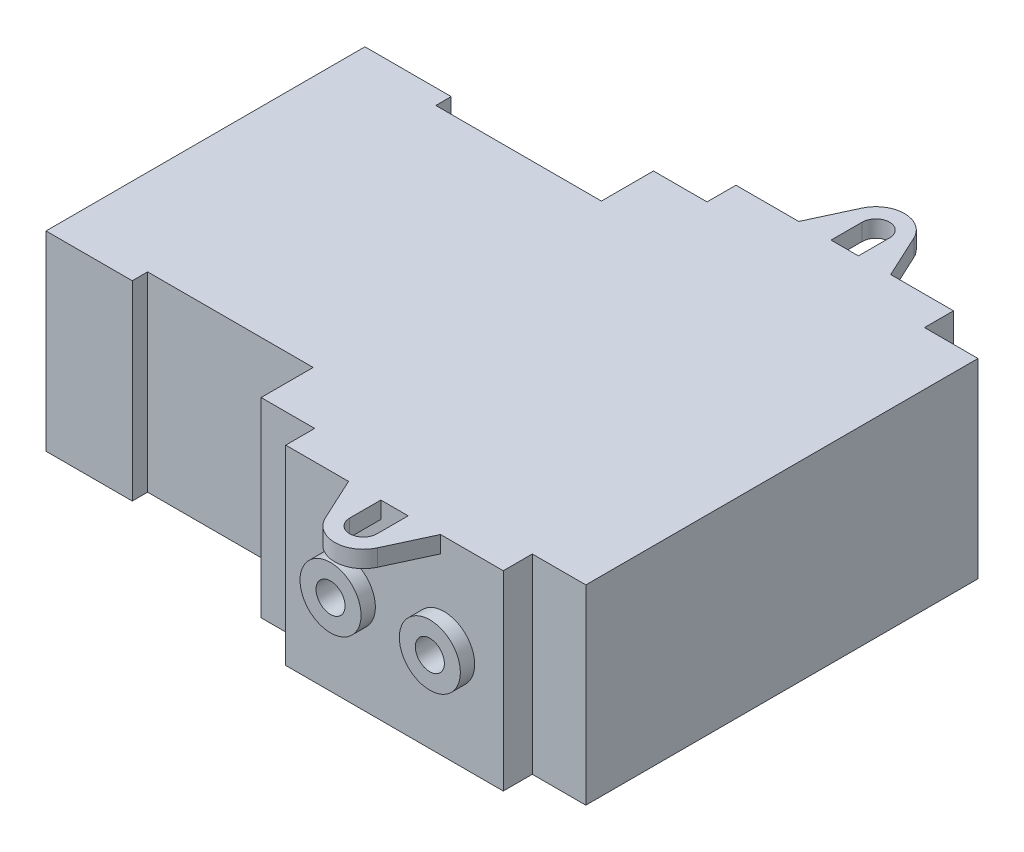
from build123d import *

# Parameters (mm, degrees)
BOSS_EXTRUDE1_DEPTH = 23.0378
SKETCH2_R           = 3.683
BOSS_EXTRUDE2_DEPTH = 1.7272
SKETCH3_R           = 1.7526
CUT_EXTRUDE1_DEPTH  = 58.8104
BOSS_EXTRUDE3_DEPTH = 2.032


with BuildPart() as part:
    # Sketch1 → Boss-Extrude1 (new body)
    with BuildSketch(Plane(origin=(0, 0, 0), x_dir=(1, 0, 0), z_dir=(0, 1, 0))):
        Polygon((-34.798, 19.2532), (-24.384, 19.2532), (-24.384, 17.399), (-4.3942, 17.399), (-4.3942, 23.684705806), (2.0701, 23.684705806), (2.0701, 27.178), (28.3337, 27.178), (28.3337, 23.6728), (34.798, 23.6728), (34.798, -23.6728), (28.3337, -23.6728), (28.3337, -27.178), (2.0701, -27.178), (2.0701, -23.684705806), (-4.3942, -23.684705806), (-4.3942, -17.399), (-24.384, -17.399), (-24.384, -19.2532), (-34.798, -19.2532), align=None)
    extrude(amount=BOSS_EXTRUDE1_DEPTH)

    # Sketch2 → Boss-Extrude2 (add)
    with BuildSketch(Plane.XY.offset(27.178)):
        with Locations((21.1963, 11.5189)):
            Circle(SKETCH2_R)
        with Locations((9.2075, 11.5189)):
            Circle(SKETCH2_R)
    boss_extrude2 = extrude(amount=BOSS_EXTRUDE2_DEPTH)

    # Mirror1: Boss-Extrude2 across plane
    add(boss_extrude2.mirror(Plane.XY))

    # Sketch3 → Cut-Extrude1 (cut, through all)
    with BuildSketch(Plane.XY.offset(28.9052)):
        with Locations((21.1963, 11.5189)):
            Circle(SKETCH3_R)
        with Locations((9.2075, 11.5189)):
            Circle(SKETCH3_R)
    extrude(amount=-CUT_EXTRUDE1_DEPTH, mode=Mode.SUBTRACT)

    # Sketch4 → Boss-Extrude3 (add)
    with BuildSketch(Plane(origin=(0, 23.0378, 0), x_dir=(1, 0, 0), z_dir=(0, 1, 0))):
        with BuildLine():
            Line((13.5509, -27.178), (9.652, -27.178))
            Line((9.652, -27.178), (12.067809158, -32.389905736))
            ThreePointArc((12.067809158, -32.389905736), (15.2019, -34.3916), (18.335990842, -32.389905736))
            Line((18.335990842, -32.389905736), (20.7518, -27.178))
            Line((20.7518, -27.178), (16.8529, -27.178))
            Line((16.8529, -27.178), (16.8529, -30.9372))
            ThreePointArc((16.8529, -30.9372), (15.2019, -32.5882), (13.5509, -30.9372))
            Line((13.5509, -30.9372), (13.5509, -27.178))
        make_face()
        with BuildLine():
            Line((16.8529, 30.9372), (16.8529, 27.178))
            Line((16.8529, 27.178), (20.7518, 27.178))
            Line((20.7518, 27.178), (18.335990842, 32.389905736))
            ThreePointArc((18.335990842, 32.389905736), (15.2019, 34.3916), (12.067809158, 32.389905736))
            Line((12.067809158, 32.389905736), (9.652, 27.178))
            Line((9.652, 27.178), (13.5509, 27.178))
            Line((13.5509, 27.178), (13.5509, 30.9372))
            ThreePointArc((13.5509, 30.9372), (15.2019, 32.5882), (16.8529, 30.9372))
        make_face()
    extrude(amount=-BOSS_EXTRUDE3_DEPTH)


solid = part.part
